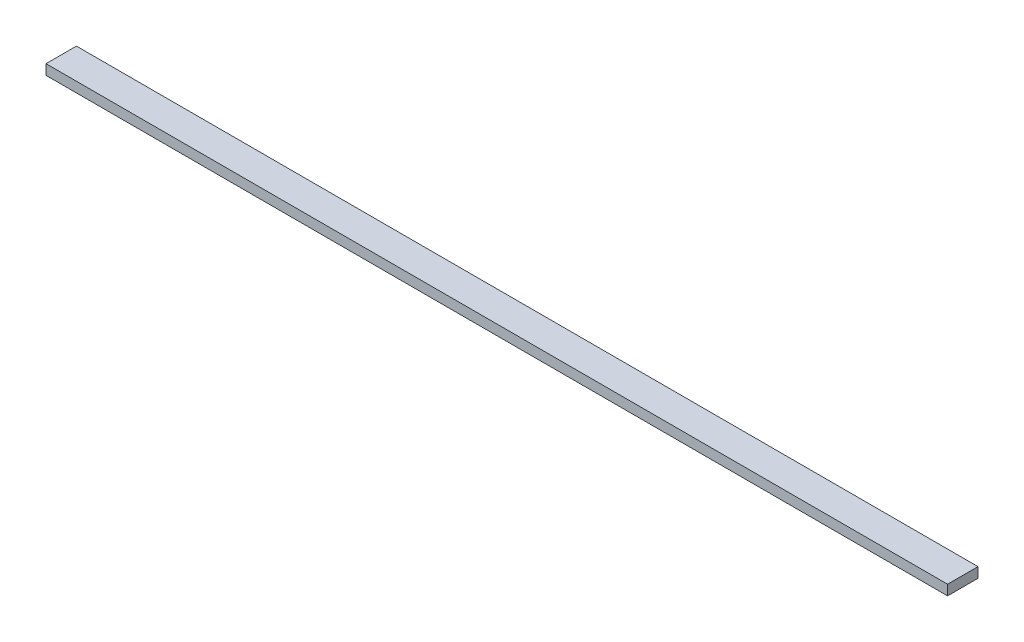
from build123d import *

# Parameters (mm, degrees)
SKETCH1_W           = 888.53
SKETCH1_H           = 30
BOSS_EXTRUDE1_DEPTH = 10


with BuildPart() as part:
    # Sketch1 → Boss-Extrude1 (new body)
    with BuildSketch(Plane(origin=(0, 0, 0), x_dir=(1, 0, 0), z_dir=(0, 1, 0))):
        Rectangle(SKETCH1_W, SKETCH1_H)
    extrude(amount=BOSS_EXTRUDE1_DEPTH)


solid = part.part
